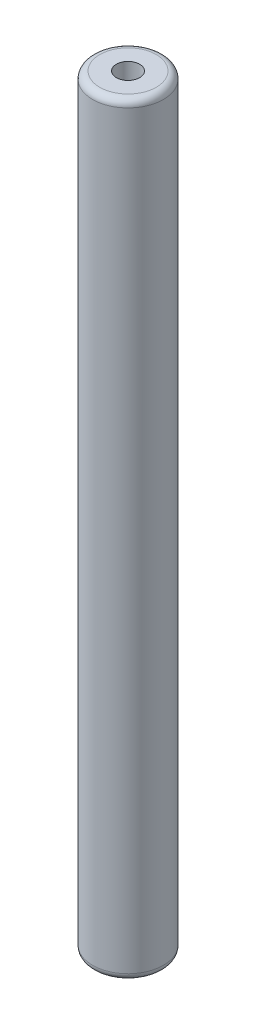
from build123d import *

# Parameters (mm, degrees)
SKETCH1_R            = 2.5
BOSS_EXTRUDE1_DEPTH  = 27
SKETCH2_R            = 0.825
CUT_EXTRUDE1_DEPTH   = 5
FILLET1_R            = 0.5
FILLET1_OF_MIRROR1_R = 0.5


with BuildPart() as part:
    # Sketch1 → Boss-Extrude1 (new body)
    with BuildSketch(Plane(origin=(0, 0, 0), x_dir=(1, 0, 0), z_dir=(0, 1, 0))):
        with Locations(Location((0, 0, 0), (0, 0, 270))):
            Circle(SKETCH1_R)
    boss_extrude1 = extrude(amount=BOSS_EXTRUDE1_DEPTH)

    # Sketch2 → Cut-Extrude1 (cut)
    with BuildSketch(Plane(origin=(0, 27, 0), x_dir=(1, 0, 0), z_dir=(0, 1, 0))):
        with Locations(Location((0, 0, 0), (0, 0, 270))):
            Circle(SKETCH2_R)
    cut_extrude1 = extrude(amount=-CUT_EXTRUDE1_DEPTH, mode=Mode.SUBTRACT)

    # Fillet1
    fillet1_edges = [part.edges().sort_by_distance(p)[0] for p in [
        (0, 27, -2.5),
    ]]
    fillet(fillet1_edges, radius=FILLET1_R)

    # Mirror1: Boss-Extrude1, Cut-Extrude1 across plane
    add(boss_extrude1.mirror(Plane.ZX))
    add(cut_extrude1.mirror(Plane.ZX), mode=Mode.SUBTRACT)

    # Fillet1 of Mirror1
    fillet1_of_mirror1_edges = [part.edges().sort_by_distance(p)[0] for p in [
        (0, -27, -2.5),
    ]]
    fillet(fillet1_of_mirror1_edges, radius=FILLET1_OF_MIRROR1_R)


solid = part.part
